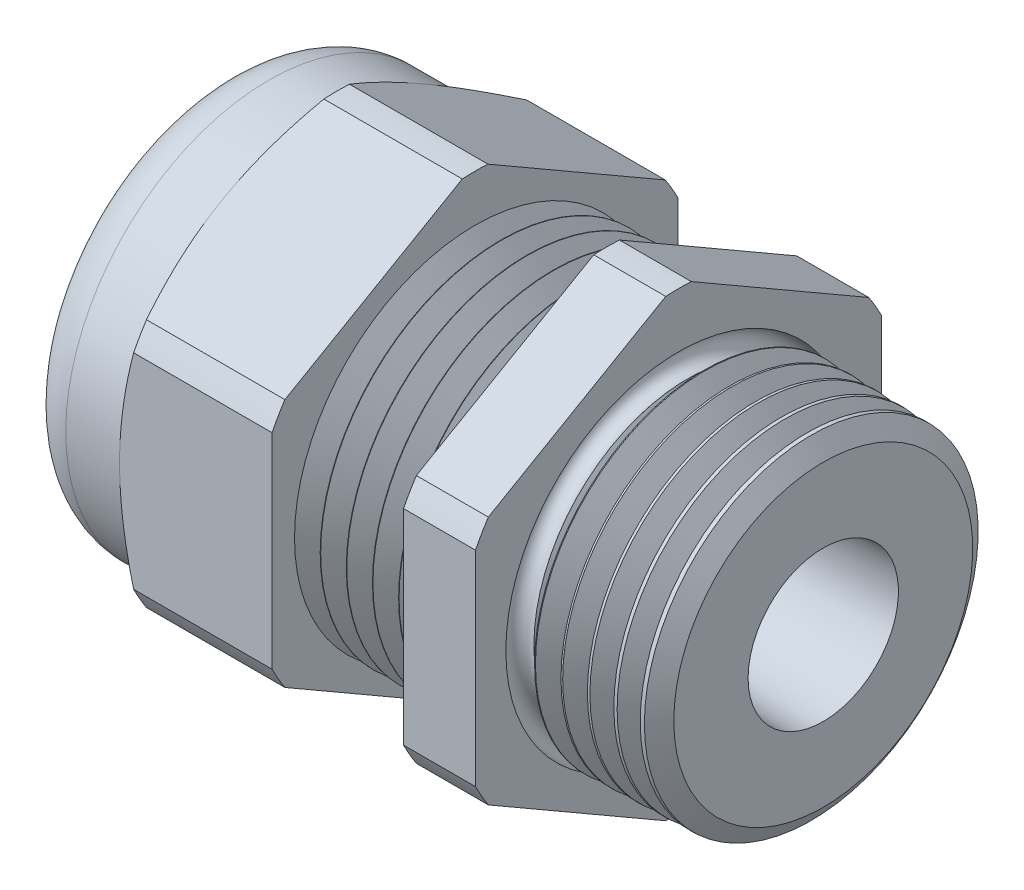
from build123d import *

# Parameters (mm, degrees)
SKETCH2_OUTSIDE_W  = 36.338
SKETCH2_OUTSIDE_H  = 36.338
CUT_EXTRUDE1_DEPTH = 19.3675
SKETCH14_W         = 5.5245
SKETCH14_H         = 1.778
CHAMFER1_SIZE      = 0.326149358
CHAMFER1_SIZE2     = 0.3175
SKETCH3_OUTSIDE_W  = 131.256
SKETCH3_OUTSIDE_H  = 133.908
SKETCH3_OUTSIDE_R  = 11.049
CUT_EXTRUDE2_DEPTH = 28.2415
CUT_EXTRUDE2_DRAFT = -60
SKETCH16_W         = 5.0165
SKETCH16_H         = 4.45135
FILLET1_R          = 2.59588
LPATTERN1_COUNT    = 6
LPATTERN1_PITCH    = 1.4224
LPATTERN2_COUNT    = 6
LPATTERN2_PITCH    = 1.4224
SKETCH15_R         = 0.635
FILLET4_R          = 0.254


with BuildPart() as part:
    # Sketch1 → Revolve1 (revolve)
    with BuildSketch(Plane.XY, mode=Mode.PRIVATE) as revolve1_sk:
        Polygon((-11.070166667, 9.82726), (-11.070166667, 12.37488), (-19.3675, 12.37488), (-19.3675, 9.271), (-24.892, 9.271), (-24.892, 7.88035), (-19.3675, 7.88035), (-19.3675, 3.429), (-11.070166667, 3.429), (7.874, 4.090544877), (7.874, 9.064812054), (0, 9.271), (0, 12.37488), (-3.917412935, 12.37488), (-3.917412935, 9.82726), align=None)
    revolve(revolve1_sk.sketch.rotate(Axis((-18.386021217, 0, 0), (1, 0, 0)), 90), axis=Axis((-18.386021217, 0, 0), (1, 0, 0)))  # turned: the seam where the file's is

    # Sketch2 outside → Cut-Extrude1 (cut)
    with BuildSketch(Plane(origin=(0, 0, 0), x_dir=(0, 0, -1), z_dir=(1, 0, 0))):
        Rectangle(SKETCH2_OUTSIDE_W, SKETCH2_OUTSIDE_H)
        with BuildLine():
            Line((11.049, -5.572903553), (11.049, 5.572903553))
            ThreePointArc((11.049, 5.572903553), (10.716960449, 6.18744), (10.35077605, 6.78226291))
            Line((10.35077605, 6.78226291), (0.69822395, 12.355166463))
            ThreePointArc((0.69822395, 12.355166463), (0, 12.37488), (-0.69822395, 12.355166463))
            Line((-0.69822395, 12.355166463), (-10.35077605, 6.78226291))
            ThreePointArc((-10.35077605, 6.78226291), (-10.716960449, 6.18744), (-11.049, 5.572903553))
            Line((-11.049, 5.572903553), (-11.049, -5.572903553))
            ThreePointArc((-11.049, -5.572903553), (-10.716960449, -6.18744), (-10.35077605, -6.78226291))
            Line((-10.35077605, -6.78226291), (-0.69822395, -12.355166463))
            ThreePointArc((-0.69822395, -12.355166463), (0, -12.37488), (0.69822395, -12.355166463))
            Line((0.69822395, -12.355166463), (10.35077605, -6.78226291))
            ThreePointArc((10.35077605, -6.78226291), (10.716960449, -6.18744), (11.049, -5.572903553))
        make_face(mode=Mode.SUBTRACT)
    extrude(amount=-CUT_EXTRUDE1_DEPTH, mode=Mode.SUBTRACT)

    # Sketch14 → Revolve4 (revolve)
    with BuildSketch(Plane.XY, mode=Mode.PRIVATE) as revolve4_sk:
        with Locations((-22.12975, 10.16)):
            Rectangle(SKETCH14_W, SKETCH14_H)
    revolve(revolve4_sk.sketch.rotate(Axis((-18.386021217, 0, 0), (1, 0, 0)), 90), axis=Axis((-18.386021217, 0, 0), (1, 0, 0)))  # turned: the seam where the file's is

    # Chamfer1
    chamfer1_edges = [part.edges().sort_by_distance(p)[0] for p in [
        (7.874, 0, -9.064812054),
    ]]
    chamfer1_side = [part.faces().sort_by_distance(p)[0] for p in [
        (3.937, 0, -9.167906027),
    ]]
    chamfer(chamfer1_edges, length=CHAMFER1_SIZE, length2=CHAMFER1_SIZE2, reference=chamfer1_side[0])


with BuildPart() as cut_extrude2_tool:
    # Sketch3 outside → Cut-Extrude2 (with draft: the straight prism first)
    with BuildSketch(Plane.ZY.offset(19.3675)):
        Rectangle(SKETCH3_OUTSIDE_W, SKETCH3_OUTSIDE_H)
        Circle(SKETCH3_OUTSIDE_R, mode=Mode.SUBTRACT)
    extrude(amount=-CUT_EXTRUDE2_DEPTH)
    # Cut-Extrude2: the draft: its side faces are tilted about the plane it starts from
    cut_extrude2_sides = [cut_extrude2_tool.faces().sort_by_distance(p)[0] for p in [
        (-5.24675, -66.954, 0),
        (-5.24675, 0, 65.628),
        (-5.24675, 66.954, 0),
        (-5.24675, 0, -65.628),
        (-5.24675, 0, -11.049),
    ]]
    draft(cut_extrude2_sides, Plane.ZY.offset(19.3675), CUT_EXTRUDE2_DRAFT)


with BuildPart() as part_1:
    add(part.part)

    # Cut-Extrude2: cut by cut_extrude2_tool
    add(cut_extrude2_tool.part, mode=Mode.SUBTRACT)

    # Fillet1
    fillet1_edges = [part_1.edges().sort_by_distance(p)[0] for p in [
        (-24.892, 0, -11.049),
    ]]
    fillet(fillet1_edges, radius=FILLET1_R)

    # Sketch10 → Cut-Revolve1 (revolve, cut)
    with BuildSketch(Plane.XY):
        Polygon((-11.070166667, 9.82726), (-10.371666992, 8.617423075), (-9.673167318, 9.82726), align=None)
    cut_revolve1 = revolve(axis=Axis((15.58962545, 0, 0), (-1, 0, 0)), mode=Mode.SUBTRACT)

    # LPattern1: Cut-Revolve1 ×6
    with Locations(*[(i * LPATTERN1_PITCH, 0, 0) for i in range(1, LPATTERN1_COUNT)]):
        add(cut_revolve1, mode=Mode.SUBTRACT)

    # Sketch13 → Cut-Revolve2 (revolve, cut)
    with BuildSketch(Plane.XY, mode=Mode.PRIVATE) as cut_revolve2_sk:
        Polygon((0, 9.271), (1.397797721, 9.234397379), (0.709465127, 8.042170354), align=None)
    cut_revolve2 = revolve(cut_revolve2_sk.sketch.rotate(Axis((-18.386021217, 0, 0), (1, 0, 0)), 270), axis=Axis((-18.386021217, 0, 0), (1, 0, 0)), mode=Mode.SUBTRACT)  # turned: the seam where the file's is

    # LPattern2: Cut-Revolve2 ×6
    with Locations(*[(i * LPATTERN2_PITCH, 0, 0) for i in range(1, LPATTERN2_COUNT)]):
        add(cut_revolve2, mode=Mode.SUBTRACT)

    # Sketch15 → Cut-Revolve4 (revolve, cut)
    with BuildSketch(Plane.XY, mode=Mode.PRIVATE) as cut_revolve4_sk:
        with Locations((0, -8.763)):
            Circle(SKETCH15_R)
    revolve(cut_revolve4_sk.sketch.rotate(Axis((10.155027747, 0, 0), (-1, 0, 0)), 180), axis=Axis((10.155027747, 0, 0), (-1, 0, 0)), mode=Mode.SUBTRACT)  # turned: the seam where the file's is


with BuildPart() as body_2:
    # Sketch16 → Revolve5 (revolve)
    with BuildSketch(Plane.XY, mode=Mode.PRIVATE) as revolve5_sk:
        with Locations((-21.87575, 5.654675)):
            Rectangle(SKETCH16_W, SKETCH16_H)
    revolve(revolve5_sk.sketch.rotate(Axis((9.562227286, 0, 0), (-1, 0, 0)), 270), axis=Axis((9.562227286, 0, 0), (-1, 0, 0)))  # turned: the seam where the file's is

    # Fillet4
    fillet4_edges = [body_2.edges().sort_by_distance(p)[0] for p in [
        (-24.384, 0, -7.88035),
    ]]
    fillet(fillet4_edges, radius=FILLET4_R)


solid = Compound([part_1.part, body_2.part])
